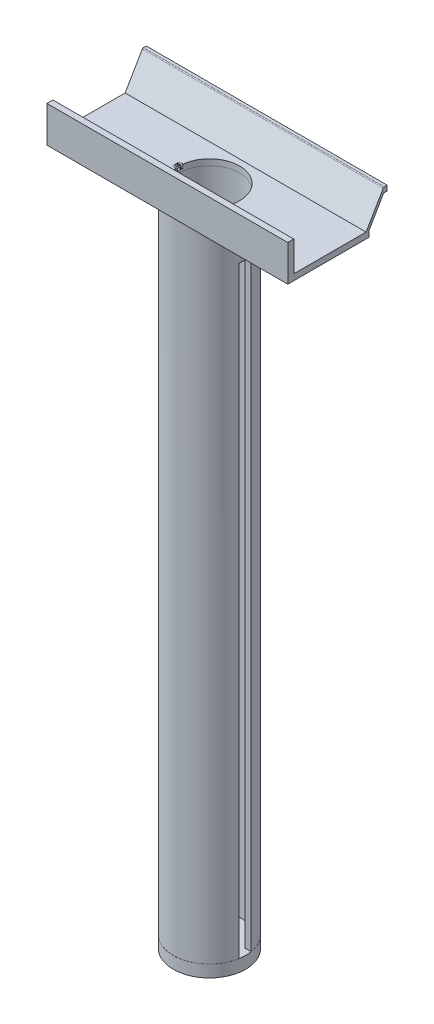
from build123d import *
from build123d.topology import SkipClean

# Parameters (mm, degrees)
SKETCH1_R                = 6
SKETCH1_R_2              = 5
BOSS_EXTRUDE1_DEPTH      = 8
BOSS_EXTRUDE1_DEPTH_BACK = 100
SKETCH2_W                = 13.568523926
SKETCH2_H                = 2.001
CUT_EXTRUDE1_DEPTH       = 100
BOSS_EXTRUDE5_DEPTH      = 20
BOSS_EXTRUDE5_DEPTH_BACK = 20
CUT_EXTRUDE3_DEPTH       = 0.301
CUT_EXTRUDE3_DEPTH_BACK  = 0.301
SKETCH4_R                = 0.2005
CUT_EXTRUDE4_DEPTH       = 0.5
CUT_EXTRUDE4_DEPTH_BACK  = 0.5
SKETCH7_R                = 6.004995175
BOSS_EXTRUDE3_DEPTH      = 2
SKETCH8_R                = 2
BOSS_EXTRUDE4_DEPTH      = 4
REVOLVE1_ANGLE           = 180
SKETCH10_R               = 1.5
CUT_EXTRUDE6_DEPTH       = 4
CUT_EXTRUDE7_START       = -2
SKETCH12_W               = 0.749531432
SKETCH12_H               = 3
CUT_EXTRUDE7_DEPTH       = 4
CIRPATTERN1_COUNT        = 4
CIRPATTERN1_ANGLE        = 135
CUT_EXTRUDE10_DEPTH      = 0.601
CUT_EXTRUDE10_DEPTH_BACK = 0.601
SKETCH17_R               = 5.0005
CUT_EXTRUDE11_DEPTH      = 1
SKETCH18_R               = 1.0005
BOSS_EXTRUDE6_DEPTH      = 3.302
CUT_EXTRUDE12_START      = -8.5
SKETCH19_W               = 1.302
SKETCH19_H               = 6.992761226
CUT_EXTRUDE12_DEPTH      = 16.5


with BuildPart() as part:
    # Sketch1 → Boss-Extrude1 (new body, two sides)
    with BuildSketch(Plane(origin=(0, 0, 0), x_dir=(1, 0, 0), z_dir=(0, 1, 0))) as boss_extrude1_sk:
        with Locations(Location((0, 0, 0), (0, 0, 270))):  # turned: the seam where the file's is
            Circle(SKETCH1_R)
        with Locations(Location((0, 0, 0), (0, 0, 270))):  # turned: the seam where the file's is
            Circle(SKETCH1_R_2, mode=Mode.SUBTRACT)
    extrude(amount=BOSS_EXTRUDE1_DEPTH)
    extrude(boss_extrude1_sk.sketch, amount=-BOSS_EXTRUDE1_DEPTH_BACK)

    # Sketch2 → Cut-Extrude1 (cut)
    with BuildSketch(Plane(origin=(0, 0, 0), x_dir=(1, 0, 0), z_dir=(0, 1, 0))):
        Rectangle(SKETCH2_W, SKETCH2_H)
    extrude(amount=-CUT_EXTRUDE1_DEPTH, mode=Mode.SUBTRACT)

    # Sketch14 → Boss-Extrude5 (add, two sides)
    with BuildSketch(Plane(origin=(0, 0, 0), x_dir=(0, 0, -1), z_dir=(1, 0, 0))) as boss_extrude5_sk:
        with BuildLine():
            Line((-7, 7), (-7, 13))
            Line((-7, 13), (-6, 13))
            Line((-6, 13), (-6, 8))
            Line((-6, 8), (6, 8))
            Line((6, 8), (8.857536784, 12.900741868))
            ThreePointArc((8.857536784, 12.900741868), (8.930683048, 12.973419107), (9.030311424, 13))
            Line((9.030311424, 13), (9.5, 13))
            Line((9.5, 13), (9.5, 12.142488402))
            Line((9.5, 12.142488402), (9.030311424, 12.142488402))
            ThreePointArc((9.030311424, 12.142488402), (8.930683048, 12.115907509), (8.857536784, 12.04323027))
            Line((8.857536784, 12.04323027), (6.5, 8))
            Line((6.5, 8), (6.5, 7))
            Line((6.5, 7), (-7, 7))
        make_face()
    extrude(amount=BOSS_EXTRUDE5_DEPTH)
    extrude(boss_extrude5_sk.sketch, amount=-BOSS_EXTRUDE5_DEPTH_BACK)

    # Sketch3 → Cut-Extrude3 (cut, two sides)
    with BuildSketch(Plane.XY) as cut_extrude3_sk:
        with BuildLine():
            Line((-5.6, 8), (-5.6, 8.797930369))
            Line((-5.6, 8.797930369), (-4.894941581, 8.797930369))
            Line((-4.894941581, 8.797930369), (-4.894941581, 7.4))
            Line((-4.894941581, 7.4), (-5, 7.4))
            Line((-5, 7.4), (-5.3, 7.4))
            ThreePointArc((-5.3, 7.4), (-5.512132034, 7.487867966), (-5.6, 7.7))
            Line((-5.6, 7.7), (-5.6, 8))
        make_face()
    extrude(amount=CUT_EXTRUDE3_DEPTH, mode=Mode.SUBTRACT)
    extrude(cut_extrude3_sk.sketch, amount=-CUT_EXTRUDE3_DEPTH_BACK, mode=Mode.SUBTRACT)

    # Sketch4 → Cut-Extrude4 (cut, two sides)
    with BuildSketch(Plane.XY) as cut_extrude4_sk:
        with Locations(Location((-5.3, 7.7, 0), (0, 0, 180))):  # turned: the seam where the file's is
            Circle(SKETCH4_R)
    extrude(amount=CUT_EXTRUDE4_DEPTH, mode=Mode.SUBTRACT)
    extrude(cut_extrude4_sk.sketch, amount=-CUT_EXTRUDE4_DEPTH_BACK, mode=Mode.SUBTRACT)

    # Sketch7 → Boss-Extrude3 (add)
    with SkipClean():  # keep this step's faces unmerged: merging them makes the solid invalid here
        with BuildSketch(Plane(origin=(0, -100, 0), x_dir=(-1, 0, 0), z_dir=(0, -1, 0))):
            with Locations(Location((0, 0, 0), (0, 0, 90))):  # turned: the seam where the file's is
                Circle(SKETCH7_R)
            with BuildLine():
                Line((0.2001, -4.995994395), (0.2001, -1.988959776))
                ThreePointArc((0.2001, -1.988959776), (0.765077034, -1.846796722), (1.26507052, -1.547771811))
                Line((1.26507052, -1.547771811), (3.391356531, -3.674057822))
                ThreePointArc((3.391356531, -3.674057822), (1.913509623, -4.619359363), (0.2001, -4.995994395))
            make_face(mode=Mode.SUBTRACT)
            with BuildLine():
                Line((-0.1999, -4.996002401), (-0.1999, -1.988979887))
                ThreePointArc((-0.1999, -1.988979887), (-0.764891326, -1.846873644), (-1.264914878, -1.547899012))
                Line((-1.264914878, -1.547899012), (-3.391209448, -3.674193582))
                ThreePointArc((-3.391209448, -3.674193582), (-1.913324699, -4.619435961), (-0.1999, -4.996002401))
            make_face(mode=Mode.SUBTRACT)
        extrude(amount=BOSS_EXTRUDE3_DEPTH)

    # Sketch8 → Boss-Extrude4 (add)
    with SkipClean():  # keep this step's faces unmerged: merging them makes the solid invalid here
        with BuildSketch(Plane(origin=(0, -102, 0), x_dir=(-1, 0, 0), z_dir=(0, -1, 0))):
            with Locations(Location((0, 0, 0), (0, 0, 90))):  # turned: the seam where the file's is
                Circle(SKETCH8_R)
        extrude(amount=-BOSS_EXTRUDE4_DEPTH)

    # Sketch9 → Revolve1 (revolve)
    with SkipClean():  # keep this step's faces unmerged: merging them makes the solid invalid here
        with BuildSketch(Plane(origin=(0, -98, 0), x_dir=(1, 0, 0), z_dir=(0, 1, 0))):
            with BuildLine():
                Line((-2, 0), (2, 0))
                ThreePointArc((2, 0), (0, 2), (-2, 0))
            make_face()
        revolve(axis=Axis((-2, -98, 0), (1, 0, 0)), revolution_arc=REVOLVE1_ANGLE)

    # Sketch10 → Cut-Extrude6 (cut)
    with SkipClean():  # keep this step's faces unmerged: merging them makes the solid invalid here
        with BuildSketch(Plane.XZ.offset(102)):
            with Locations(Location((0, 0, 0), (0, 0, 270))):  # turned: the seam where the file's is
                Circle(SKETCH10_R)
        extrude(amount=-CUT_EXTRUDE6_DEPTH, mode=Mode.SUBTRACT)

    # Sketch11 → Cut-Revolve3 (revolve, cut)
    with SkipClean():  # keep this step's faces unmerged: merging them makes the solid invalid here
        with BuildSketch(Plane.XZ.offset(98)):
            with BuildLine():
                Line((0, -1.5), (0, 1.5))
                ThreePointArc((0, 1.5), (-1.5, 0), (0, -1.5))
            make_face()
        revolve(axis=Axis((0, -98, -1.5), (0, 0, 1)), mode=Mode.SUBTRACT)

    # Sketch12 → Cut-Extrude7 (cut)
    with SkipClean():  # keep this step's faces unmerged: merging them makes the solid invalid here
        with BuildSketch(Plane(origin=(0, 0, 0), x_dir=(0, 0, -1), z_dir=(1, 0, 0)).offset(CUT_EXTRUDE7_START)):
            with Locations((0, -98)):
                Rectangle(SKETCH12_W, SKETCH12_H)
        cut_extrude7 = extrude(amount=CUT_EXTRUDE7_DEPTH, mode=Mode.SUBTRACT)

    # CirPattern1: Cut-Extrude7 ×4 about axis
    with SkipClean():  # keep this step's faces unmerged: merging them makes the solid invalid here
        cirpattern1_axis = Axis((0, 0, 0), (0, -1, 0))
        for i in range(1, CIRPATTERN1_COUNT):
            add(cut_extrude7.rotate(cirpattern1_axis, i * CIRPATTERN1_ANGLE / (CIRPATTERN1_COUNT - 1)), mode=Mode.SUBTRACT)

    # Sketch16 → Cut-Extrude10 (cut, two sides)
    with SkipClean():  # keep this step's faces unmerged: merging them makes the solid invalid here
        with BuildSketch(Plane.XY) as cut_extrude10_sk:
            with BuildLine():
                Line((-5.3, 7.99), (-5.6, 7.99))
                Line((-5.6, 7.99), (-5.6, 8.300814289))
                Line((-5.6, 8.300814289), (-4.858660394, 8.300814289))
                Line((-4.858660394, 8.300814289), (-4.858660394, 7.4))
                Line((-4.858660394, 7.4), (-5.01, 7.4))
                Line((-5.01, 7.4), (-5.01, 7.7))
                ThreePointArc((-5.01, 7.7), (-5.094939033, 7.905060967), (-5.3, 7.99))
            make_face()
        extrude(amount=CUT_EXTRUDE10_DEPTH, mode=Mode.SUBTRACT)
        extrude(cut_extrude10_sk.sketch, amount=-CUT_EXTRUDE10_DEPTH_BACK, mode=Mode.SUBTRACT)

    # Sketch17 → Cut-Extrude11 (cut)
    with SkipClean():  # keep this step's faces unmerged: merging them makes the solid invalid here
        with BuildSketch(Plane(origin=(0, 8, 0), x_dir=(1, 0, 0), z_dir=(0, 1, 0))):
            with Locations(Location((0, 0, 0), (0, 0, 186.902951629))):  # turned: the seam where the file's is
                Circle(SKETCH17_R)
        extrude(amount=-CUT_EXTRUDE11_DEPTH, mode=Mode.SUBTRACT)

    # Sketch18 → Boss-Extrude6 (add)
    with SkipClean():  # keep this step's faces unmerged: merging them makes the solid invalid here
        with BuildSketch(Plane(origin=(6, 0, 0), x_dir=(0, 0, -1), z_dir=(1, 0, 0))):
            with BuildLine():
                Line((1, 3.5), (1, 7))
                Line((1, 7), (5, 7))
                Line((5, 7), (5, 3.5))
                ThreePointArc((5, 3.5), (3, 1.5), (1, 3.5))
            make_face()
            with Locations((3, 3.5)):
                Circle(SKETCH18_R, mode=Mode.SUBTRACT)
        boss_extrude6 = extrude(amount=BOSS_EXTRUDE6_DEPTH)

    # Sketch19 → Cut-Extrude12 (cut)
    with SkipClean():  # keep this step's faces unmerged: merging them makes the solid invalid here
        with BuildSketch(Plane.XY.offset(-1).offset(CUT_EXTRUDE12_START)):
            with Locations((7.651, 3.5)):
                Rectangle(SKETCH19_W, SKETCH19_H)
        cut_extrude12 = extrude(amount=CUT_EXTRUDE12_DEPTH, mode=Mode.SUBTRACT)

    # Mirror1: Boss-Extrude6, Cut-Extrude12 across plane
    with SkipClean():  # keep this step's faces unmerged: merging them makes the solid invalid here
        add(boss_extrude6.mirror(Plane(origin=(0, 0, 0), x_dir=(0, 0, 1), z_dir=(1, 0, 0))))
        add(cut_extrude12.mirror(Plane(origin=(0, 0, 0), x_dir=(0, 0, 1), z_dir=(1, 0, 0))), mode=Mode.SUBTRACT)


solid = part.part
